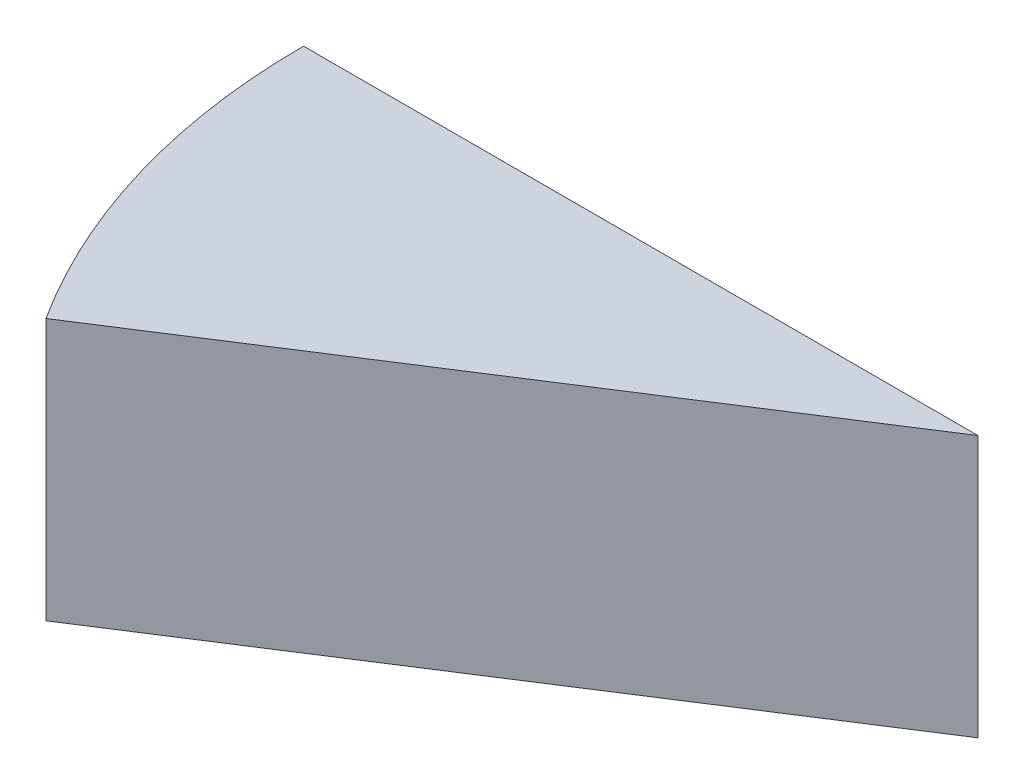
from build123d import *

# Parameters (mm, degrees)
BOSS_EXTRUDE1_DEPTH = 30


with BuildPart() as part:
    # Sketch1 → Boss-Extrude1 (new body)
    with BuildSketch(Plane(origin=(0, 0, 0), x_dir=(1, 0, 0), z_dir=(0, 1, 0))):
        with BuildLine():
            Line((-77.282855011, 0), (0, 0))
            Line((0, 0), (-65.014474805, -41.782265908))
            ThreePointArc((-65.014474805, -41.782265908), (-74.152356363, -21.773096342), (-77.282855011, 0))
        make_face()
    extrude(amount=BOSS_EXTRUDE1_DEPTH)


solid = part.part
